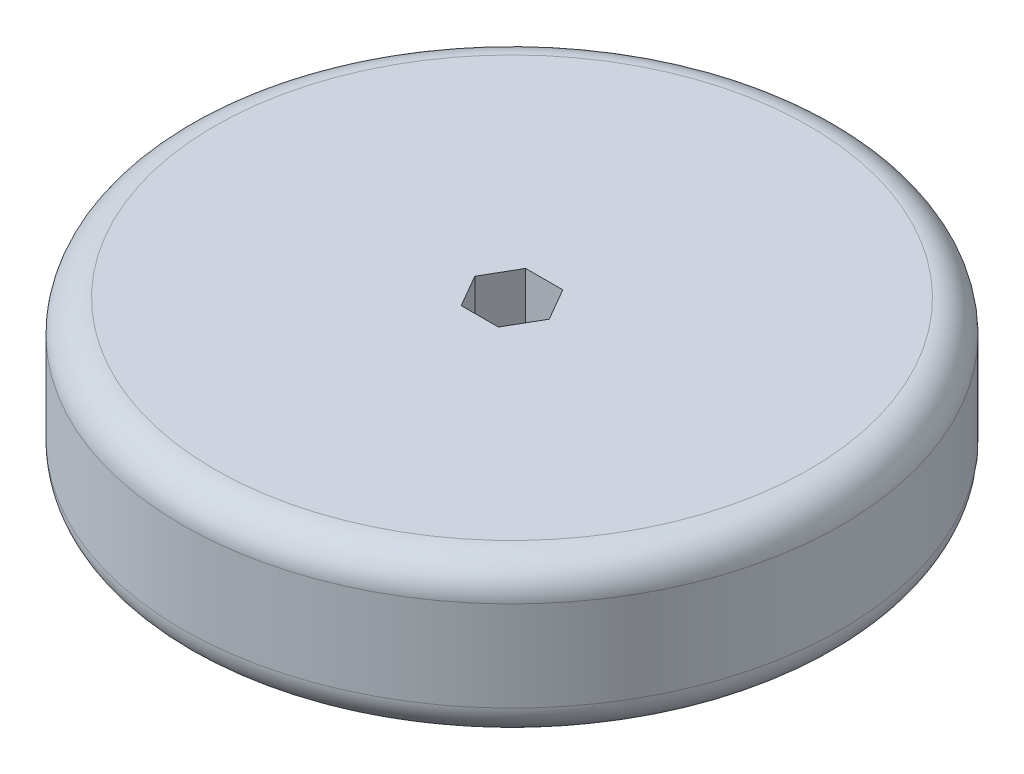
from build123d import *

# Parameters (mm, degrees)
SKETCH1_R           = 64.9605
BOSS_EXTRUDE1_DEPTH = 15.24
CUT_EXTRUDE1_DEPTH  = 30.48
FILLET1_R           = 6.35


with BuildPart() as part:
    # Sketch1 → Boss-Extrude1 (new, symmetric)
    with BuildSketch(Plane(origin=(0, 0, 0), x_dir=(1, 0, 0), z_dir=(0, 1, 0))):
        Circle(SKETCH1_R)
    extrude(amount=BOSS_EXTRUDE1_DEPTH, both=True)

    # Sketch2 → Cut-Extrude1 (cut)
    with BuildSketch(Plane(origin=(0, 15.24, 0), x_dir=(1, 0, 0), z_dir=(0, 1, 0))):
        Polygon((7.332348419, 8.887e-06), (3.666166513, 6.350004444), (-3.666181906, 6.349995556), (-7.332348419, -8.887e-06), (-3.666166513, -6.350004444), (3.666181906, -6.349995556), align=None)
    extrude(amount=-CUT_EXTRUDE1_DEPTH, mode=Mode.SUBTRACT)

    # Fillet1
    fillet1_edges = [part.edges().sort_by_distance(p)[0] for p in [
        (-64.9605, -15.24, 0),
        (-64.9605, 15.24, 0),
    ]]
    fillet(fillet1_edges, radius=FILLET1_R)


solid = part.part
